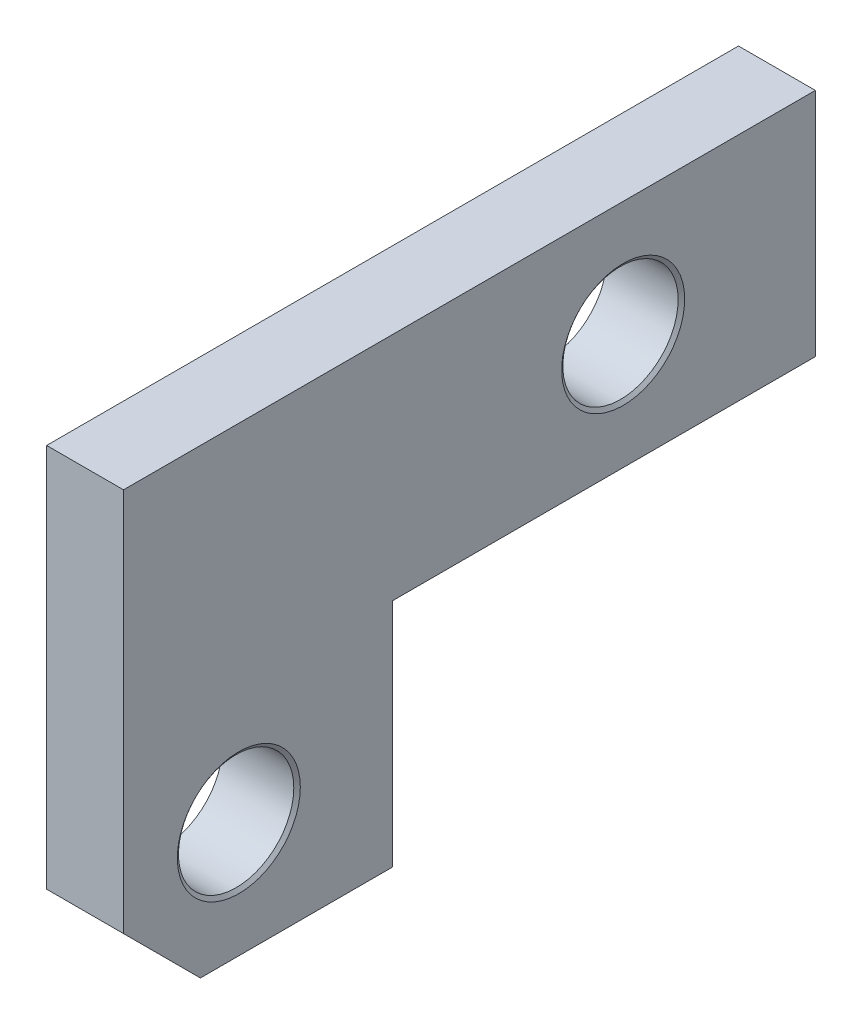
from build123d import *

# Parameters (mm, degrees)
EXTRUDE_1_DEPTH            = 2
HOLE_WIZARD_M31_AT_2_COUNT = 2
HOLE_WIZARD_M31_AT_2_PITCH = 11.66190379
CHAMFER_2_SIZE             = 2


with BuildPart() as part:
    # Эскиз1 → Бобышка-Вытянуть1 (new body)
    with BuildSketch(Plane(origin=(0, 0, 0), x_dir=(0, 0, -1), z_dir=(1, 0, 0))):
        Polygon((-9, -6), (-2, -6), (-2, 0), (9, 0), (9, 6), (-9, 6), align=None)
    extrude(amount=EXTRUDE_1_DEPTH)

    # Эскиз2 → Отверстие обработанное метчиком M31 (revolve, cut)
    with BuildSketch(Plane(origin=(2, 3, -4), x_dir=(0, 0, -1), z_dir=(0, 1, 0))):
        Polygon((0, 0), (0, 2), (1.6, 2), (1.5, 1.929979246), (1.5, 0.070020754), (1.6, 0), align=None)
    hole_wizard_m31 = revolve(axis=Axis((8.35, 3, -4), (-1, 0, 0)), mode=Mode.SUBTRACT)

    # Отверстие обработанное метчиком M31 at 2: Отверстие обработанное метчиком M31 ×2
    with Locations(*[Vector(0, -0.514495755, 0.857492926) * (i * HOLE_WIZARD_M31_AT_2_PITCH) for i in range(1, HOLE_WIZARD_M31_AT_2_COUNT)]):
        add(hole_wizard_m31, mode=Mode.SUBTRACT)

    # Фаска2
    chamfer_2_edges = [part.edges().sort_by_distance(p)[0] for p in [
        (1, -6, 9),
    ]]
    chamfer(chamfer_2_edges, length=CHAMFER_2_SIZE)


solid = part.part
